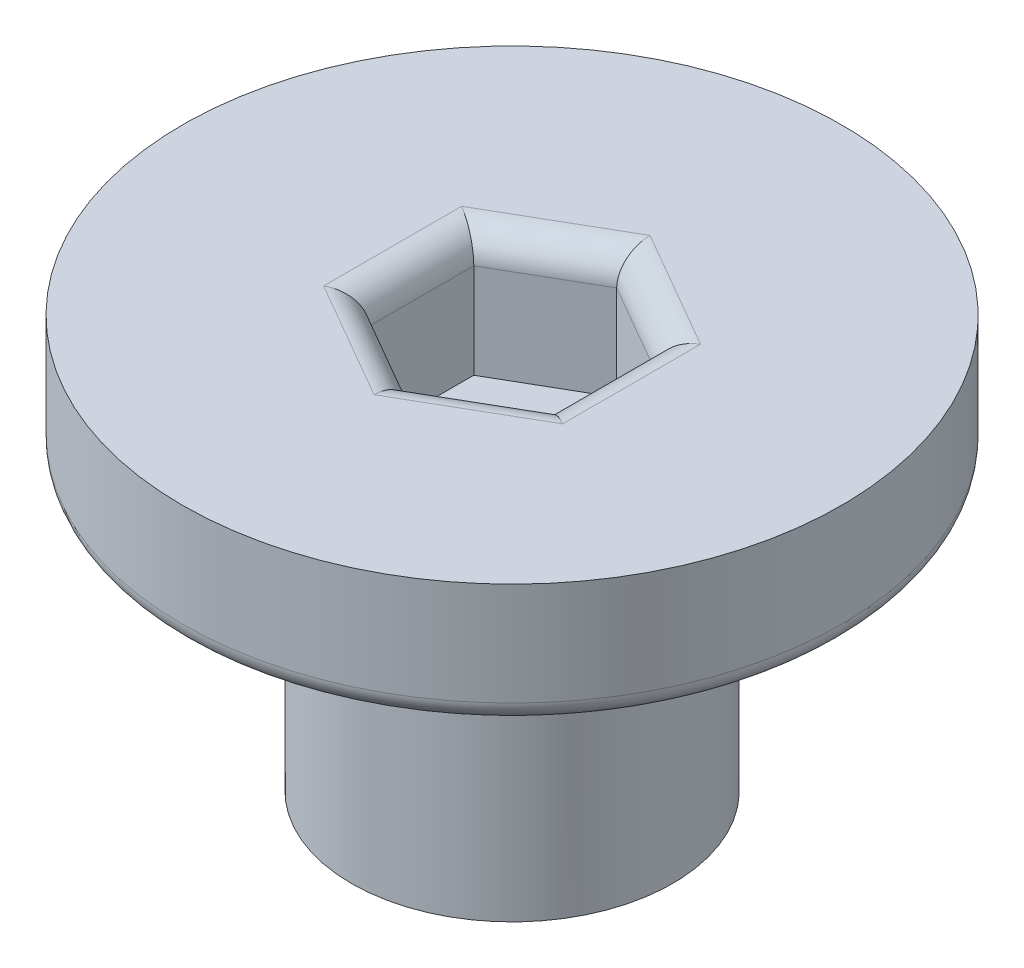
from build123d import *

# Parameters (mm, degrees)
SKETCH1_R           = 8
BOSS_EXTRUDE1_DEPTH = 3
SKETCH2_R           = 3.9
BOSS_EXTRUDE2_DEPTH = 7
SKETCH3_R           = 1.15
CUT_EXTRUDE3_DEPTH  = 12
CUT_EXTRUDE4_DEPTH  = 3
FILLET1_R           = 0.7
FILLET2_R           = 0.5
FILLET3_R           = 0.5


with BuildPart() as part:
    # Sketch1 → Boss-Extrude1 (new body)
    with BuildSketch(Plane(origin=(0, 0, 0), x_dir=(1, 0, 0), z_dir=(0, 1, 0))):
        Circle(SKETCH1_R)
    extrude(amount=BOSS_EXTRUDE1_DEPTH)

    # Sketch2 → Boss-Extrude2 (add)
    with BuildSketch(Plane.XZ):
        Circle(SKETCH2_R)
    extrude(amount=BOSS_EXTRUDE2_DEPTH)

    # Sketch3 → Cut-Extrude3 (cut)
    with BuildSketch(Plane.XZ.offset(7)):
        Circle(SKETCH3_R)
    extrude(amount=-CUT_EXTRUDE3_DEPTH, mode=Mode.SUBTRACT)

    # Sketch6 → Cut-Extrude4 (cut)
    with BuildSketch(Plane(origin=(0, 3, 0), x_dir=(1, 0, 0), z_dir=(0, 1, 0))):
        Polygon((0, 2.540341184), (-2.2, 1.270170592), (-2.2, -1.270170592), (0, -2.540341184), (2.2, -1.270170592), (2.2, 1.270170592), align=None)
    extrude(amount=-CUT_EXTRUDE4_DEPTH, mode=Mode.SUBTRACT)

    # Fillet1
    fillet1_edges = [part.edges().sort_by_distance(p)[0] for p in [
        (1.1, 3, -1.905255888),
        (-1.1, 3, -1.905255888),
        (-2.2, 3, 0),
        (-1.1, 3, 1.905255888),
        (1.1, 3, 1.905255888),
        (2.2, 3, 0),
    ]]
    fillet(fillet1_edges, radius=FILLET1_R)

    # Fillet2
    fillet2_edges = [part.edges().sort_by_distance(p)[0] for p in [
        (-1.15, -7, 0),
    ]]
    fillet(fillet2_edges, radius=FILLET2_R)

    # Fillet3
    fillet3_edges = [part.edges().sort_by_distance(p)[0] for p in [
        (-8, 0, 0),
        (-3.9, 0, 0),
    ]]
    fillet(fillet3_edges, radius=FILLET3_R)


solid = part.part
